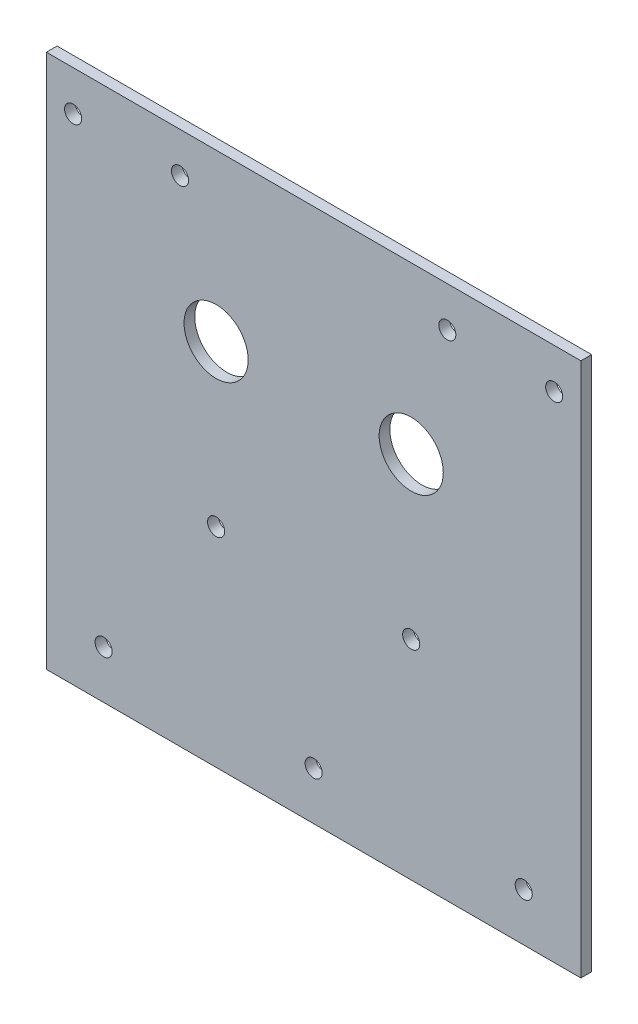
from build123d import *

# Parameters (mm, degrees)
SKETCH_1_W          = 100
SKETCH_1_H          = 100
EXTRUDE_1_DEPTH     = 2
SKETCH_2_R          = 1.6
CUT_EXTRUDE_1_DEPTH = 2
SKETCH_3_R          = 1.6
CUT_EXTRUDE_2_DEPTH = 10
SKETCH_4_R          = 6
CUT_EXTRUDE_3_DEPTH = 38.65
SKETCH_5_R          = 1.6
CUT_EXTRUDE_4_DEPTH = 38.6
SKETCH_6_R          = 1.6
CUT_EXTRUDE_5_DEPTH = 10


with BuildPart() as part:
    # ｽｹｯﾁ1 → ﾎﾞｽ - 押し出し1 (new body)
    with BuildSketch(Plane.XY):
        Rectangle(SKETCH_1_W, SKETCH_1_H)
    extrude(amount=EXTRUDE_1_DEPTH)

    # ｽｹｯﾁ2 → ｶｯﾄ - 押し出し1 (cut)
    with BuildSketch(Plane.XY.offset(2)):
        with Locations((-45, 42.5)):
            Circle(SKETCH_2_R)
        with Locations((-25, 42.5)):
            Circle(SKETCH_2_R)
        with Locations((25, 42.5)):
            Circle(SKETCH_2_R)
        with Locations((45, 42.5)):
            Circle(SKETCH_2_R)
    extrude(amount=-CUT_EXTRUDE_1_DEPTH, mode=Mode.SUBTRACT)

    # ｽｹｯﾁ3 → ｶｯﾄ - 押し出し2 (cut)
    with BuildSketch(Plane.XY.offset(2)):
        with Locations((0, -41)):
            Circle(SKETCH_3_R)
    extrude(amount=-CUT_EXTRUDE_2_DEPTH, mode=Mode.SUBTRACT)

    # ｽｹｯﾁ4 → ｶｯﾄ - 押し出し3 (cut)
    with BuildSketch(Plane.XY.offset(2)):
        with Locations((-18.25, 19)):
            Circle(SKETCH_4_R)
        with Locations((18.25, 19)):
            Circle(SKETCH_4_R)
    extrude(amount=-CUT_EXTRUDE_3_DEPTH, mode=Mode.SUBTRACT)

    # ｽｹｯﾁ5 → ｶｯﾄ - 押し出し4 (cut)
    with BuildSketch(Plane.XY.offset(2)):
        with Locations((-18.25, -11)):
            Circle(SKETCH_5_R)
        with Locations((18.25, -11)):
            Circle(SKETCH_5_R)
    extrude(amount=-CUT_EXTRUDE_4_DEPTH, mode=Mode.SUBTRACT)

    # ｽｹｯﾁ6 → ｶｯﾄ - 押し出し5 (cut)
    with BuildSketch(Plane.XY.offset(2)):
        with Locations((-39.3, -41)):
            Circle(SKETCH_6_R)
        with Locations((39.3, -41)):
            Circle(SKETCH_6_R)
    extrude(amount=-CUT_EXTRUDE_5_DEPTH, mode=Mode.SUBTRACT)


solid = part.part
